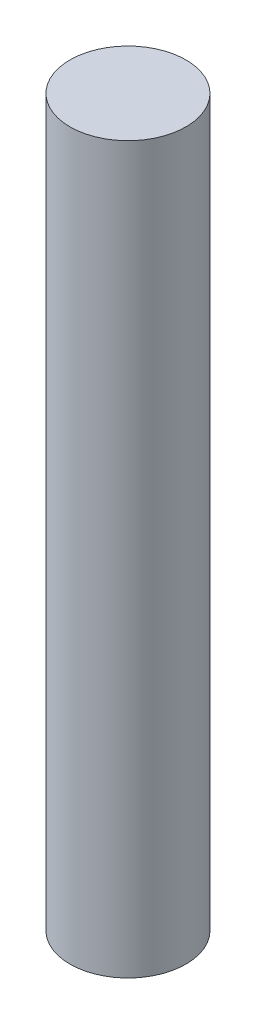
from build123d import *

# Parameters (mm, degrees)
SKETCH1_R           = 3.048
BOSS_EXTRUDE1_DEPTH = 38.1


with BuildPart() as part:
    # Sketch1 → Boss-Extrude1 (new body)
    with BuildSketch(Plane(origin=(0, 0, 0), x_dir=(1, 0, 0), z_dir=(0, 1, 0))):
        Circle(SKETCH1_R)
    extrude(amount=BOSS_EXTRUDE1_DEPTH)


solid = part.part
